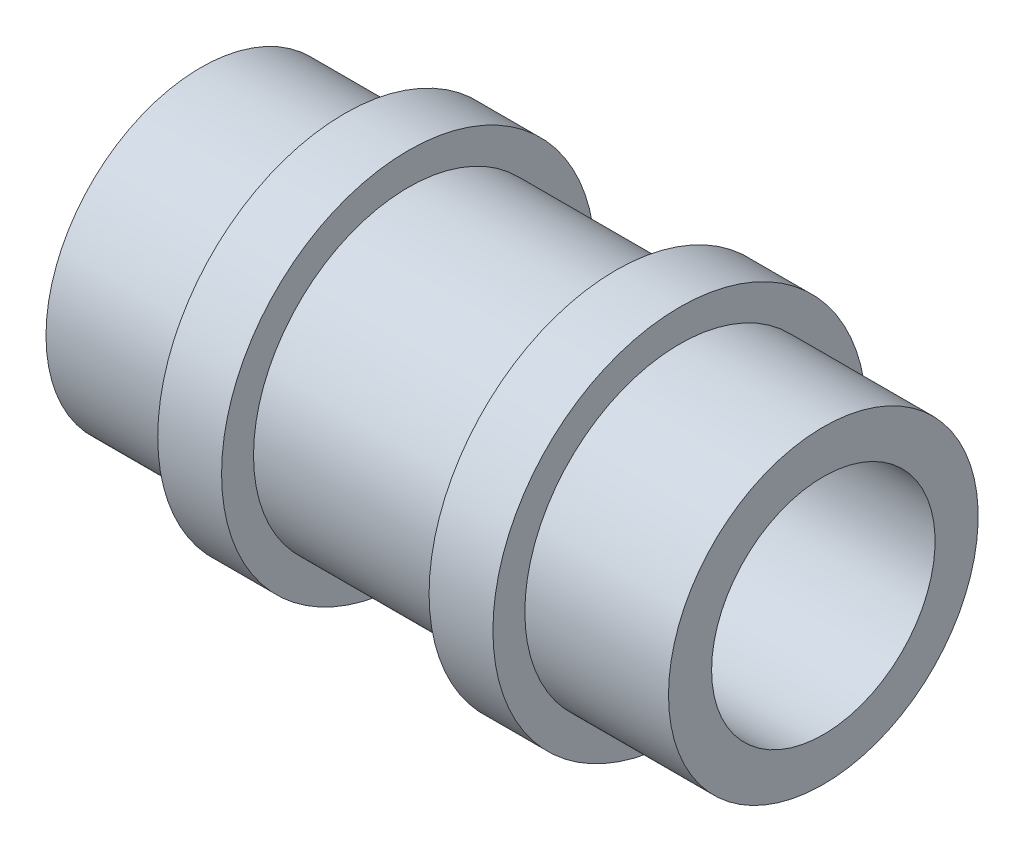
from build123d import *


with BuildPart() as part:
    # Skica1 → Rotovat1 (revolve)
    with BuildSketch(Plane.XY):
        Polygon((0, 3.5), (9.75, 3.5), (9.75, 4.85), (5.25, 4.85), (5.25, 5.85), (3.25, 5.85), (3.25, 4.85), (-3.25, 4.85), (-3.25, 5.85), (-5.25, 5.85), (-5.25, 4.85), (-9.75, 4.85), (-9.75, 3.5), align=None)
    revolve(axis=Axis((0, 0, 0), (1, 0, 0)))


solid = part.part
